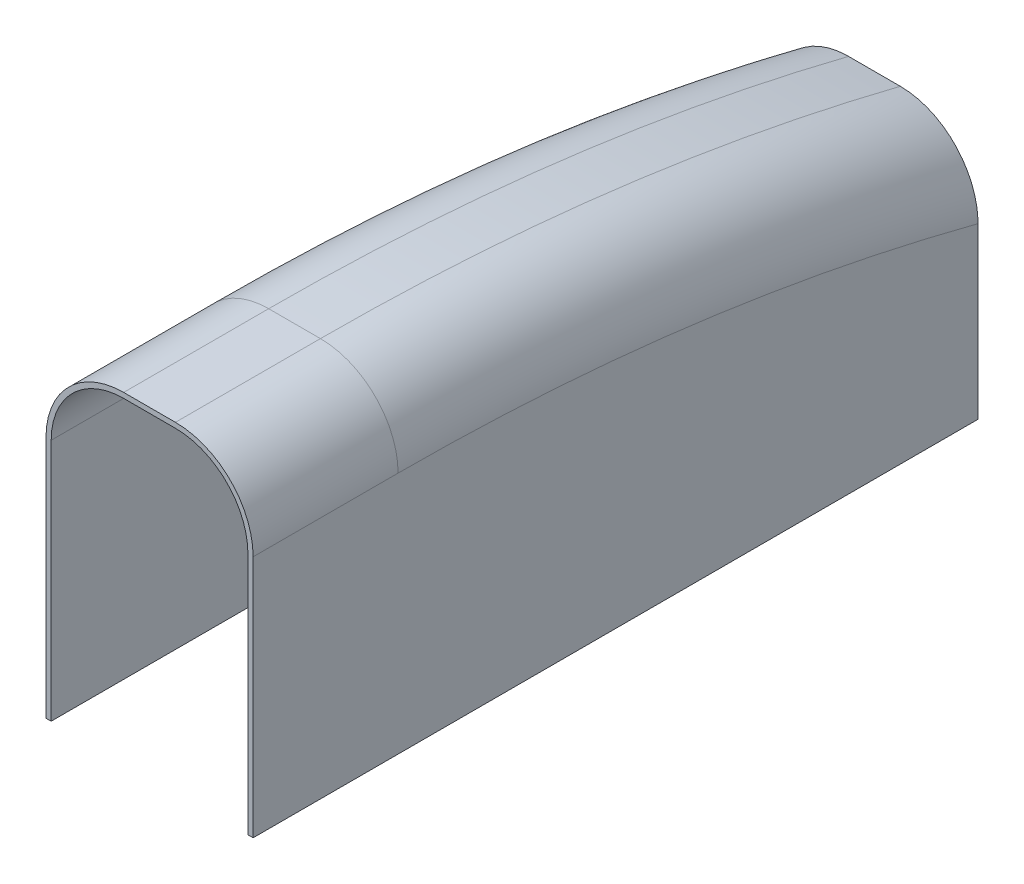
from build123d import *

# Parameters (mm, degrees)
BOSS_EXTRUDE1_DEPTH      = 25.4
BOSS_EXTRUDE1_DEPTH_BACK = 25.4
FILLET1_R                = 19.05
SHELL1_T                 = -1.27
SKETCH4_R                = 5.5626
CUT_EXTRUDE1_DEPTH       = 50.947471892


with BuildPart() as part:
    # Sketch3 → Boss-Extrude1 (new body, two sides)
    with BuildSketch(Plane(origin=(0, 0, 0), x_dir=(0, 0, -1), z_dir=(1, 0, 0))) as boss_extrude1_sk:
        with BuildLine():
            Line((0, 39.37), (35.56, 39.37))
            ThreePointArc((35.56, 39.37), (107.217829782, 34.971995328), (177.8, 21.844))
            Line((177.8, 21.844), (177.8, -39.37))
            Line((177.8, -39.37), (0, -39.37))
            Line((0, -39.37), (0, 39.37))
        make_face()
    extrude(amount=BOSS_EXTRUDE1_DEPTH)
    extrude(boss_extrude1_sk.sketch, amount=-BOSS_EXTRUDE1_DEPTH_BACK)

    # Fillet1
    fillet1_edges = [part.edges().sort_by_distance(p)[0] for p in [
        (25.4, 34.971995328, -107.217829782),
        (-25.4, 39.37, -17.78),
        (-25.4, 34.971995328, -107.217829782),
        (25.4, 39.37, -17.78),
    ]]
    fillet(fillet1_edges, radius=FILLET1_R)

    # Shell1
    shell1_openings = [part.faces().sort_by_distance(p)[0] for p in [
        (0, -39.37, -88.9),
        (0, 8.088461394, 0),
    ]]
    offset(amount=SHELL1_T, openings=shell1_openings, kind=Kind.INTERSECTION)

    # Sketch4 → Cut-Extrude1 (cut)
    with BuildSketch(Plane(origin=(0, 0, -177.8), x_dir=(-1, 0, 0), z_dir=(0, 0, -1))):
        with Locations((0, -11.577471892)):
            Circle(SKETCH4_R)
    extrude(amount=-CUT_EXTRUDE1_DEPTH, mode=Mode.SUBTRACT)


solid = part.part
